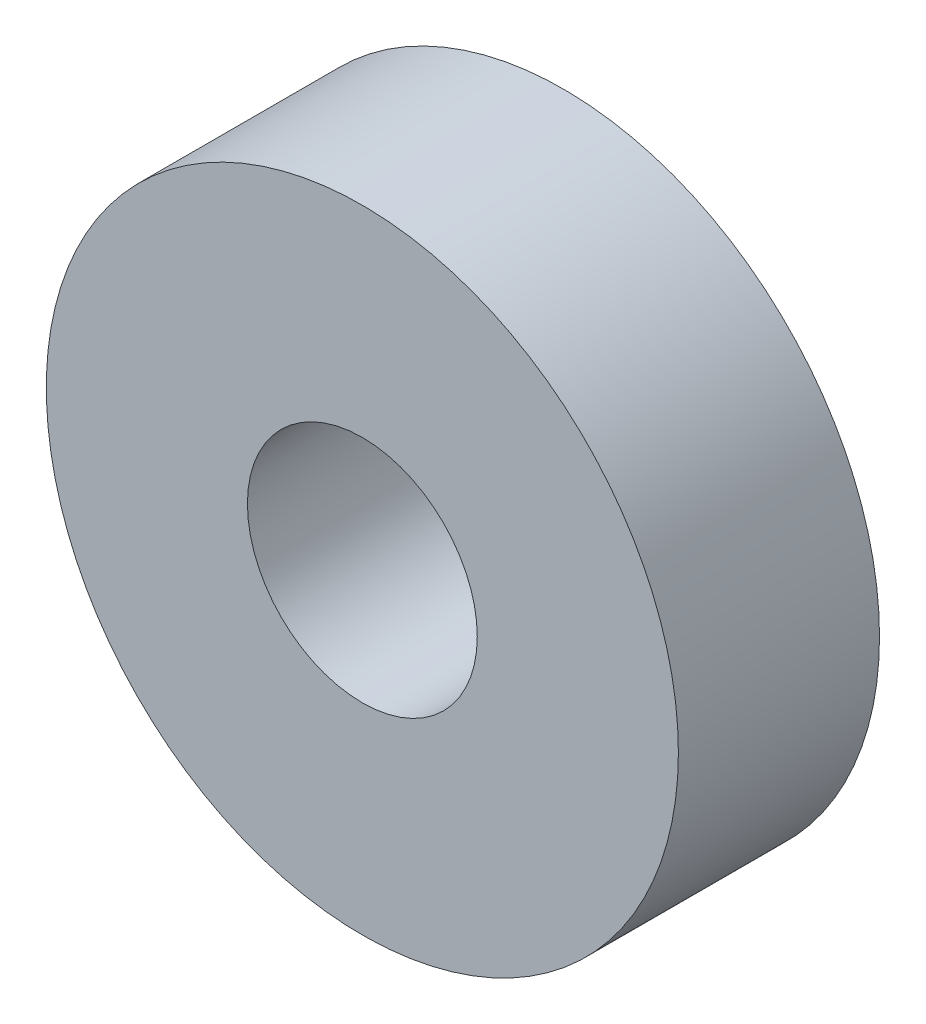
from build123d import *

# Parameters (mm, degrees)
SKETCH1_R           = 11
SKETCH1_R_2         = 4
BOSS_EXTRUDE1_DEPTH = 7
SCALE1_SCALE        = 0.571428571


with BuildPart() as part:
    # Sketch1 → Boss-Extrude1 (new body)
    with BuildSketch(Plane.XY):
        Circle(SKETCH1_R)
        Circle(SKETCH1_R_2, mode=Mode.SUBTRACT)
    extrude(amount=BOSS_EXTRUDE1_DEPTH)


with BuildPart() as part_1:
    # Scale1: scaled about (0, 0, 3.5)
    add(part.part.scale(SCALE1_SCALE).moved(Location((0, 0, 1.5))))


solid = part_1.part
